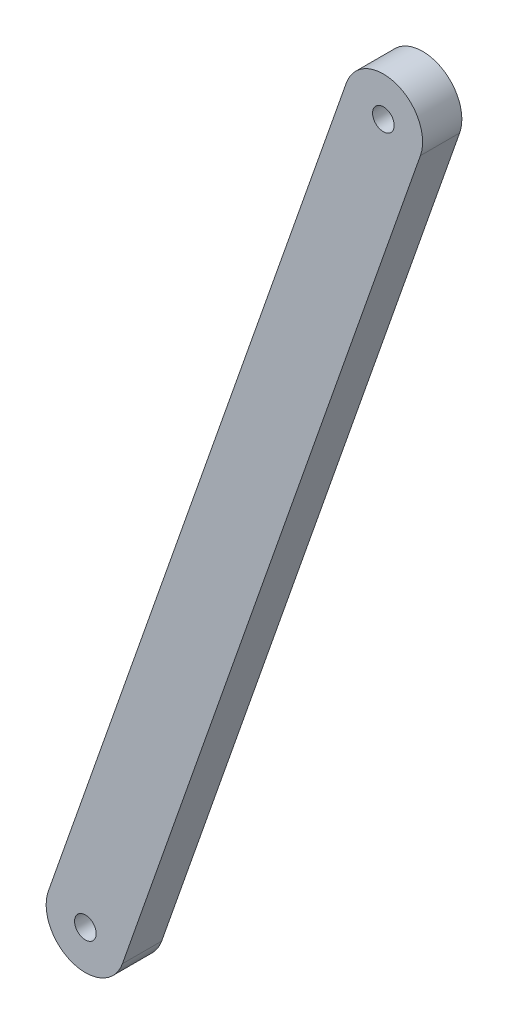
from build123d import *

# Parameters (mm, degrees)
SKETCH3_R           = 1.75
BOSS_EXTRUDE1_DEPTH = 6.35


with BuildPart() as part:
    # Sketch3 → Boss-Extrude1 (new body)
    with BuildSketch(Plane.XY):
        with BuildLine():
            Line((71.148095027, 257.589257462), (119.379587764, 394.981288438))
            ThreePointArc((119.379587764, 394.981288438), (127.474453458, 398.869494889), (131.362659908, 390.774629195))
            Line((131.362659908, 390.774629195), (83.131167171, 253.382598219))
            ThreePointArc((83.131167171, 253.382598219), (75.036301477, 249.494391769), (71.148095027, 257.589257462))
        make_face()
        with Locations((77.139631099, 255.485927841)):
            Circle(SKETCH3_R, mode=Mode.SUBTRACT)
        with Locations((125.371123836, 392.877958817)):
            Circle(SKETCH3_R, mode=Mode.SUBTRACT)
    extrude(amount=BOSS_EXTRUDE1_DEPTH)


solid = part.part
